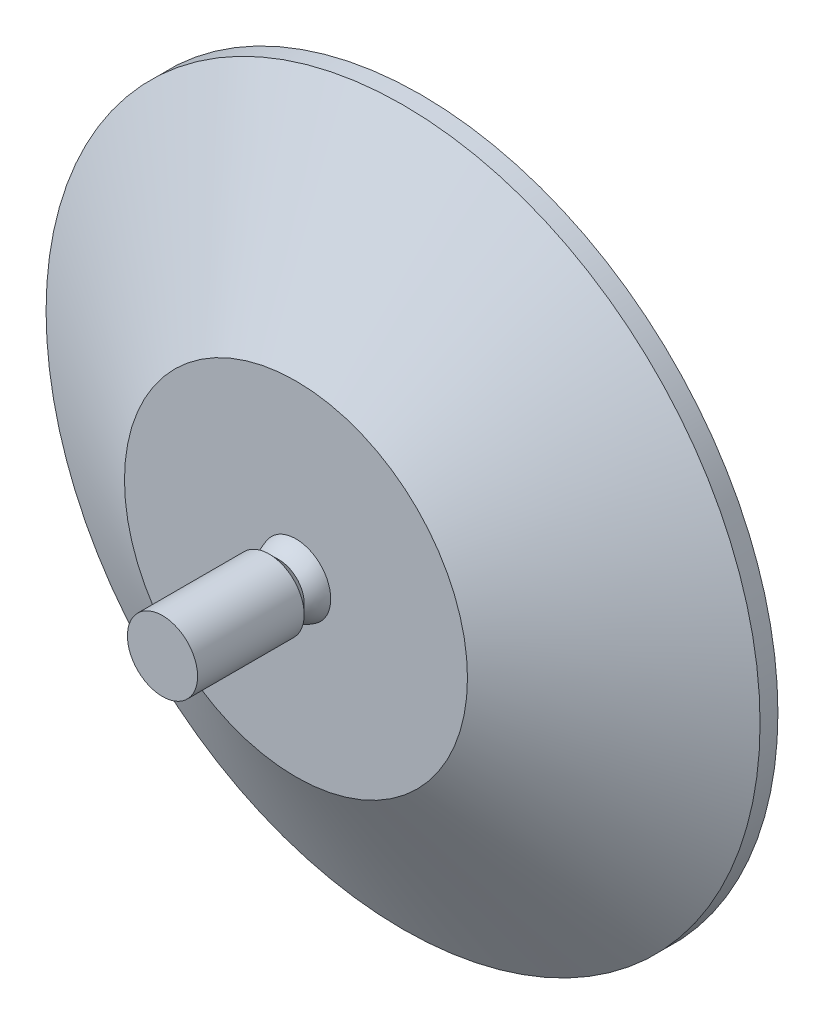
from build123d import *

# Parameters (mm, degrees)
ESQUISSE1_R        = 40
BOSS_EXTRU_1_DEPTH = 2
ESQUISSE2_R        = 40
BOSS_EXTRU_2_DEPTH = 12
BOSS_EXTRU_2_TAPER = 60


with BuildPart() as part:
    # Esquisse1 → Boss.-Extru.1 (new body)
    with BuildSketch(Plane.XY):
        Circle(ESQUISSE1_R)
    extrude(amount=BOSS_EXTRU_1_DEPTH)

    # Esquisse2 → Boss.-Extru.2 (add)
    with BuildSketch(Plane.XY.offset(2)):
        Circle(ESQUISSE2_R)
    extrude(amount=BOSS_EXTRU_2_DEPTH, taper=BOSS_EXTRU_2_TAPER)

    # Esquisse3 → Révolution1 (revolve)
    with BuildSketch(Plane(origin=(0, 0, 0), x_dir=(1, 0, 0), z_dir=(0, 1, 0))):
        with BuildLine():
            Line((2.828427125, -15.907299026), (3.932041335, -17.010913236))
            Line((3.932041335, -17.010913236), (3.932041335, -28.955760853))
            Line((3.932041335, -28.955760853), (0, -28.955760853))
            Line((0, -28.955760853), (0, -9.078871902))
            ThreePointArc((0, -9.078871902), (3.69551813, -11.548138172), (2.828427125, -15.907299026))
        make_face()
    revolve(axis=Axis((0, 0, 28.955760853), (0, 0, -1)))


solid = part.part
